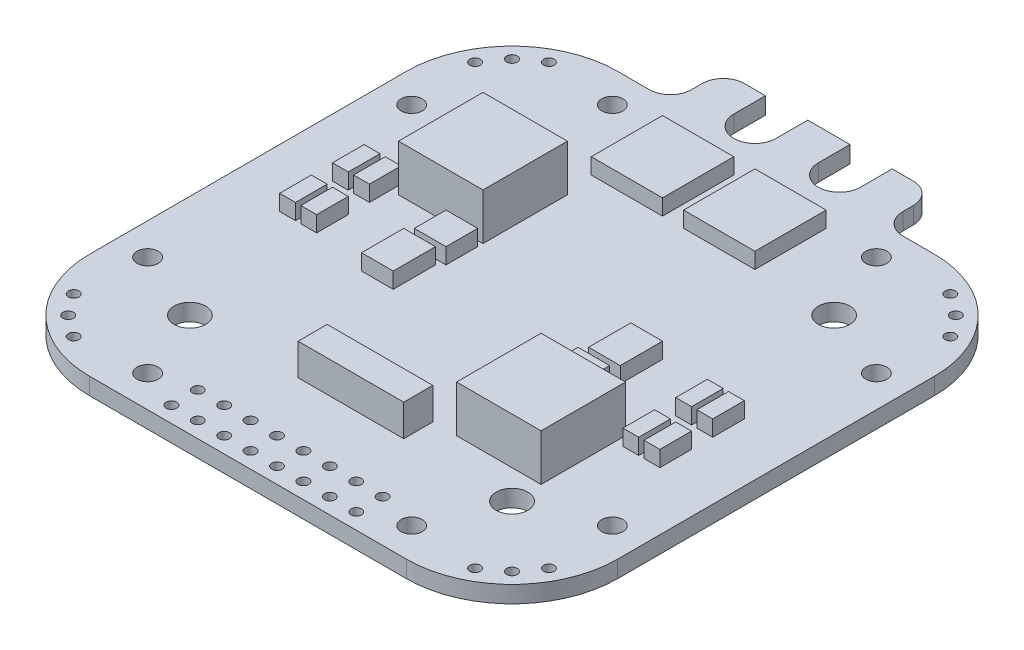
from build123d import *

# Parameters (mm, degrees)
SKETCH1_R           = 1.5
SKETCH1_R_2         = 1
SKETCH1_R_3         = 0.5
BOSS_EXTRUDE1_DEPTH = 1.6
BOSS_EXTRUDE2_START = 1.6
SKETCH2_W           = 8
SKETCH2_H           = 8
BOSS_EXTRUDE2_DEPTH = 4.4
SKETCH3_W           = 10
SKETCH3_H           = 2.75
BOSS_EXTRUDE3_DEPTH = 3
SKETCH4_W           = 6.75
SKETCH4_H           = 6.75
SKETCH4_W_2         = 3
SKETCH4_H_2         = 3
SKETCH4_H_3         = 4
SKETCH4_W_3         = 1.5
BOSS_EXTRUDE4_DEPTH = 1.5


with BuildPart() as part:
    # Sketch1 → Boss-Extrude1 (new body)
    with BuildSketch(Plane(origin=(0, 0, 0), x_dir=(1, 0, 0), z_dir=(0, 1, 0))):
        with BuildLine():
            Line((-10, 28), (-10, 27))
            ThreePointArc((-10, 27), (-10.585786438, 25.585786438), (-12, 25))
            Line((-12, 25), (-15, 25))
            ThreePointArc((-15, 25), (-22.071067812, 22.071067812), (-25, 15))
            Line((-25, 15), (-25, -15))
            ThreePointArc((-25, -15), (-22.071067812, -22.071067812), (-15, -25))
            Line((-15, -25), (15, -25))
            ThreePointArc((15, -25), (22.071067812, -22.071067812), (25, -15))
            Line((25, -15), (25, 15))
            ThreePointArc((25, 15), (22.071067812, 22.071067812), (15, 25))
            Line((15, 25), (12, 25))
            ThreePointArc((12, 25), (10.585786438, 25.585786438), (10, 27))
            Line((10, 27), (10, 28))
            ThreePointArc((10, 28), (9.414213562, 29.414213562), (8, 30))
            Line((8, 30), (6, 30))
            Line((6, 30), (6, 27))
            ThreePointArc((6, 27), (4, 25), (2, 27))
            Line((2, 27), (2, 30))
            Line((2, 30), (-2, 30))
            Line((-2, 30), (-2, 27))
            ThreePointArc((-2, 27), (-4, 25), (-6, 27))
            Line((-6, 27), (-6, 30))
            Line((-6, 30), (-8, 30))
            ThreePointArc((-8, 30), (-9.414213562, 29.414213562), (-10, 28))
        make_face()
        with Locations((15.25, -15.25)):
            Circle(SKETCH1_R, mode=Mode.SUBTRACT)
        with Locations((-15.25, -15.25)):
            Circle(SKETCH1_R, mode=Mode.SUBTRACT)
        with Locations((-15.25, 15.25)):
            Circle(SKETCH1_R, mode=Mode.SUBTRACT)
        with Locations((15.25, 15.25)):
            Circle(SKETCH1_R, mode=Mode.SUBTRACT)
        with Locations((22, 12.5)):
            Circle(SKETCH1_R_2, mode=Mode.SUBTRACT)
        with Locations((22, -12.5)):
            Circle(SKETCH1_R_2, mode=Mode.SUBTRACT)
        with Locations((12.5, -22)):
            Circle(SKETCH1_R_2, mode=Mode.SUBTRACT)
        with Locations((-12.5, -22)):
            Circle(SKETCH1_R_2, mode=Mode.SUBTRACT)
        with Locations((-22, -12.5)):
            Circle(SKETCH1_R_2, mode=Mode.SUBTRACT)
        with Locations((-22, 12.5)):
            Circle(SKETCH1_R_2, mode=Mode.SUBTRACT)
        with Locations((-12.5, 22)):
            Circle(SKETCH1_R_2, mode=Mode.SUBTRACT)
        with Locations((12.5, 22)):
            Circle(SKETCH1_R_2, mode=Mode.SUBTRACT)
        with Locations((-1.25, -23.5)):
            Circle(SKETCH1_R_3, mode=Mode.SUBTRACT)
        with Locations((1.25, -23.5)):
            Circle(SKETCH1_R_3, mode=Mode.SUBTRACT)
        with Locations((-3.75, -23.5)):
            Circle(SKETCH1_R_3, mode=Mode.SUBTRACT)
        with Locations((-6.25, -23.5)):
            Circle(SKETCH1_R_3, mode=Mode.SUBTRACT)
        with Locations((-8.75, -23.5)):
            Circle(SKETCH1_R_3, mode=Mode.SUBTRACT)
        with Locations((3.75, -23.5)):
            Circle(SKETCH1_R_3, mode=Mode.SUBTRACT)
        with Locations((6.25, -23.5)):
            Circle(SKETCH1_R_3, mode=Mode.SUBTRACT)
        with Locations((8.75, -23.5)):
            Circle(SKETCH1_R_3, mode=Mode.SUBTRACT)
        with Locations((-8.75, -21)):
            Circle(SKETCH1_R_3, mode=Mode.SUBTRACT)
        with Locations((-6.25, -21)):
            Circle(SKETCH1_R_3, mode=Mode.SUBTRACT)
        with Locations((-3.75, -21)):
            Circle(SKETCH1_R_3, mode=Mode.SUBTRACT)
        with Locations((-1.25, -21)):
            Circle(SKETCH1_R_3, mode=Mode.SUBTRACT)
        with Locations((1.25, -21)):
            Circle(SKETCH1_R_3, mode=Mode.SUBTRACT)
        with Locations((3.75, -21)):
            Circle(SKETCH1_R_3, mode=Mode.SUBTRACT)
        with Locations((6.25, -21)):
            Circle(SKETCH1_R_3, mode=Mode.SUBTRACT)
        with Locations((8.75, -21)):
            Circle(SKETCH1_R_3, mode=Mode.SUBTRACT)
        with Locations((-21.01040764, -21.01040764)):
            Circle(SKETCH1_R_3, mode=Mode.SUBTRACT)
        with Locations((-19.001894566, -22.498989257)):
            Circle(SKETCH1_R_3, mode=Mode.SUBTRACT)
        with Locations((-22.498989257, -19.001894566)):
            Circle(SKETCH1_R_3, mode=Mode.SUBTRACT)
        with Locations((-19.001894566, 22.498989257)):
            Circle(SKETCH1_R_3, mode=Mode.SUBTRACT)
        with Locations((-21.01040764, 21.01040764)):
            Circle(SKETCH1_R_3, mode=Mode.SUBTRACT)
        with Locations((-22.498989257, 19.001894566)):
            Circle(SKETCH1_R_3, mode=Mode.SUBTRACT)
        with Locations((22.498989257, 19.001894566)):
            Circle(SKETCH1_R_3, mode=Mode.SUBTRACT)
        with Locations((21.01040764, 21.01040764)):
            Circle(SKETCH1_R_3, mode=Mode.SUBTRACT)
        with Locations((19.001894566, 22.498989257)):
            Circle(SKETCH1_R_3, mode=Mode.SUBTRACT)
        with Locations((19.001894566, -22.498989257)):
            Circle(SKETCH1_R_3, mode=Mode.SUBTRACT)
        with Locations((21.01040764, -21.01040764)):
            Circle(SKETCH1_R_3, mode=Mode.SUBTRACT)
        with Locations((22.498989257, -19.001894566)):
            Circle(SKETCH1_R_3, mode=Mode.SUBTRACT)
    extrude(amount=BOSS_EXTRUDE1_DEPTH)

    # Sketch2 → Boss-Extrude2 (add)
    with BuildSketch(Plane(origin=(0, 0, 0), x_dir=(1, 0, 0), z_dir=(0, 1, 0)).offset(BOSS_EXTRUDE2_START)):
        with Locations((-11.25, 8.5)):
            Rectangle(SKETCH2_W, SKETCH2_H)
        with Locations((11.25, -8.5)):
            Rectangle(SKETCH2_W, SKETCH2_H)
    extrude(amount=BOSS_EXTRUDE2_DEPTH)

    # Sketch3 → Boss-Extrude3 (add)
    with BuildSketch(Plane(origin=(0, 1.6, 0), x_dir=(1, 0, 0), z_dir=(0, 1, 0))):
        with Locations((0, -13.875)):
            Rectangle(SKETCH3_W, SKETCH3_H)
    extrude(amount=BOSS_EXTRUDE3_DEPTH)

    # Sketch4 → Boss-Extrude4 (add)
    with BuildSketch(Plane(origin=(0, 1.6, 0), x_dir=(1, 0, 0), z_dir=(0, 1, 0))):
        with Locations((-4.375, 18.625)):
            Rectangle(SKETCH4_W, SKETCH4_H)
        with Locations((4.375, 18.625)):
            Rectangle(SKETCH4_W, SKETCH4_H)
        with Locations((8.75, -2.5)):
            Rectangle(SKETCH4_W_2, SKETCH4_H_2)
        with Locations((9.25, 1.5)):
            Rectangle(SKETCH4_W_2, SKETCH4_H_3)
        with Locations((16.75, -4)):
            Rectangle(SKETCH4_W_3, SKETCH4_H_2)
        with Locations((-9.25, -1.5)):
            Rectangle(SKETCH4_W_2, SKETCH4_H_3)
        with Locations((16.75, 1)):
            Rectangle(SKETCH4_W_3, SKETCH4_H_2)
        with Locations((18.75, 1)):
            Rectangle(SKETCH4_W_3, SKETCH4_H_2)
        with Locations((18.75, -4)):
            Rectangle(SKETCH4_W_3, SKETCH4_H_2)
        with Locations((-8.75, 2.5)):
            Rectangle(SKETCH4_W_2, SKETCH4_H_2)
        with Locations((-16.75, -1)):
            Rectangle(SKETCH4_W_3, SKETCH4_H_2)
        with Locations((-18.75, -1)):
            Rectangle(SKETCH4_W_3, SKETCH4_H_2)
        with Locations((-16.75, 4)):
            Rectangle(SKETCH4_W_3, SKETCH4_H_2)
        with Locations((-18.75, 4)):
            Rectangle(SKETCH4_W_3, SKETCH4_H_2)
    extrude(amount=BOSS_EXTRUDE4_DEPTH)


solid = part.part
